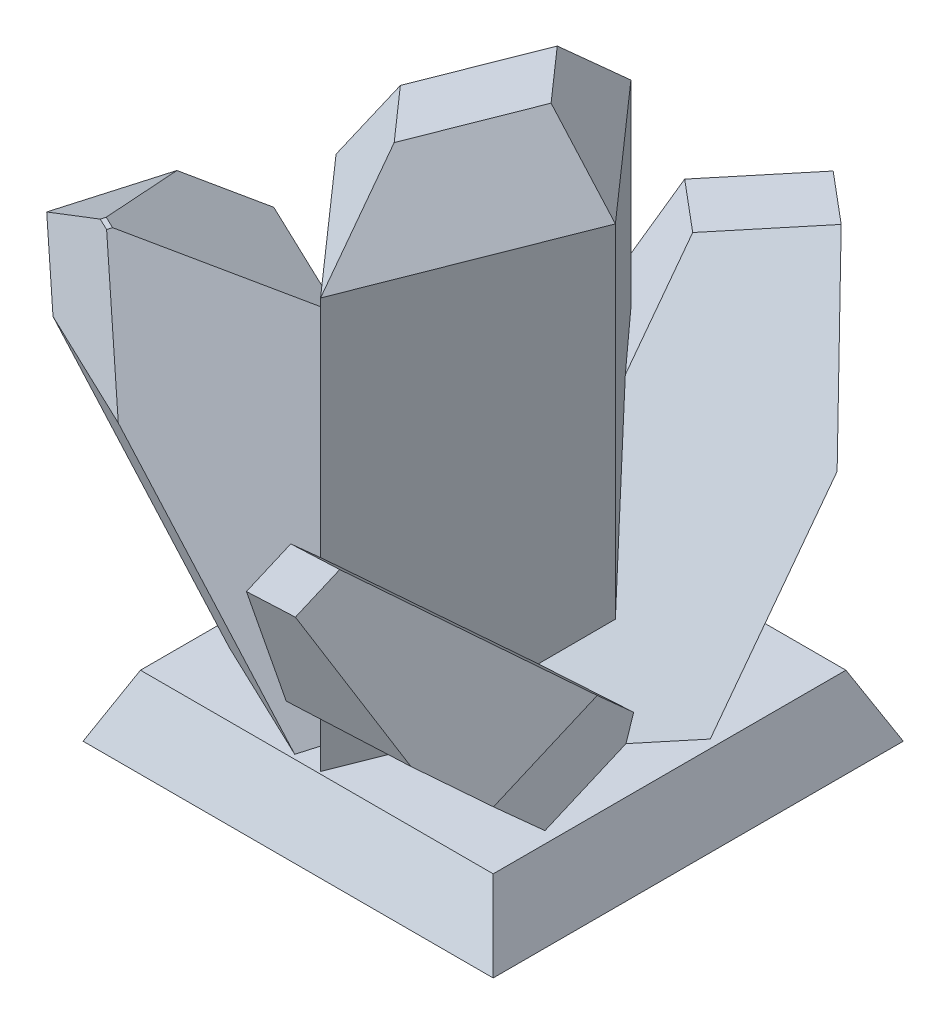
from build123d import *
from OCP.BRepFilletAPI import BRepFilletAPI_MakeChamfer

# Parameters (mm, degrees)
SKETCH1_W           = 10
SKETCH1_H           = 10
BOSS_EXTRUDE1_DEPTH = 1.5
BOSS_EXTRUDE1_TAPER = 25
BOSS_EXTRUDE2_DEPTH = 12
CHAMFER1_SIZE       = 2
CHAMFER1_SIZE2      = 1.154700538
BOSS_EXTRUDE3_DEPTH = 10
CHAMFER2_SIZE       = 3
CHAMFER2_SIZE2      = 2.406716572
CHAMFER2_SIZE2_2    = 1.500380386
CHAMFER2_SIZE2_3    = 1.516874639
BOSS_EXTRUDE4_DEPTH = 8
BOSS_EXTRUDE5_DEPTH = 10
CHAMFER3_SIZE       = 4
CHAMFER3_SIZE2      = 2.031521954
CHAMFER3_SIZE2_2    = 2.008940765
CHAMFER3_SIZE2_3    = 2.098992436
CHAMFER3_SIZE2_4    = 2.518260147


with BuildPart() as part:
    # Sketch1 → Boss-Extrude1 (new body)
    with BuildSketch(Plane(origin=(0, 0, 0), x_dir=(1, 0, 0), z_dir=(0, 1, 0))):
        Rectangle(SKETCH1_W, SKETCH1_H)
    extrude(amount=BOSS_EXTRUDE1_DEPTH, taper=BOSS_EXTRUDE1_TAPER)

    # Sketch2 → Boss-Extrude2 (add)
    with BuildSketch(Plane(origin=(0, 1.5, 0), x_dir=(1, 0, 0), z_dir=(0, 1, 0))):
        Polygon((-2.812986954, -1.017959657), (-0.78305427, 4.14157821), (2.064873257, 0.914552857), (0.034940573, -4.24498501), align=None)
    extrude(amount=BOSS_EXTRUDE2_DEPTH)

    # Chamfer1: one chamfer whose edges measure the first distance from different faces: ONE call of the kernel's chamfer builder (chamfer() names one face for all edges)
    chamfer1_edges_1 = [part.edges().sort_by_distance(p)[0] for p in [
        (-1.389023191, 13.5, 2.631472333),
    ]]
    chamfer1_side_1 = [part.faces().sort_by_distance(p)[0] for p in [
        (-1.389023191, 7.5, 2.631472333),
    ]]
    chamfer1_edges_2 = [part.edges().sort_by_distance(p)[0] for p in [
        (1.049906915, 13.5, 1.665216077),
    ]]
    chamfer1_side_2 = [part.faces().sort_by_distance(p)[0] for p in [
        (1.049906915, 7.5, 1.665216077),
    ]]
    chamfer1_edges_3 = [part.edges().sort_by_distance(p)[0] for p in [
        (0.640909494, 13.5, -2.528065533),
    ]]
    chamfer1_side_3 = [part.faces().sort_by_distance(p)[0] for p in [
        (0.640909494, 7.5, -2.528065533),
    ]]
    chamfer1_edges_4 = [part.edges().sort_by_distance(p)[0] for p in [
        (-1.798020612, 13.5, -1.561809276),
    ]]
    chamfer1_side_4 = [part.faces().sort_by_distance(p)[0] for p in [
        (-1.798020612, 7.5, -1.561809276),
    ]]
    chamfer1 = BRepFilletAPI_MakeChamfer(part.part.solid().wrapped)
    for e in chamfer1_edges_1:
        chamfer1.Add(CHAMFER1_SIZE, CHAMFER1_SIZE2, e.wrapped, chamfer1_side_1[0].wrapped)  # the first distance lies on this face
    for e in chamfer1_edges_2:
        chamfer1.Add(CHAMFER1_SIZE, CHAMFER1_SIZE2, e.wrapped, chamfer1_side_2[0].wrapped)  # the first distance lies on this face
    for e in chamfer1_edges_3:
        chamfer1.Add(CHAMFER1_SIZE, CHAMFER1_SIZE2, e.wrapped, chamfer1_side_3[0].wrapped)  # the first distance lies on this face
    for e in chamfer1_edges_4:
        chamfer1.Add(CHAMFER1_SIZE, CHAMFER1_SIZE2, e.wrapped, chamfer1_side_4[0].wrapped)  # the first distance lies on this face
    add(Compound.cast(chamfer1.Shape()), mode=Mode.REPLACE)

    # Sketch4 → Boss-Extrude3 (add, along a direction that is not the sketch's normal)
    with BuildSketch(Plane(origin=(0, 1.5, 0), x_dir=(1, 0, 0), z_dir=(0, 1, 0))):
        Polygon((-3.685896684, -2.744355022), (-2.381707977, 1.767077084), (0.661288248, 0.315446351), (-0.642900459, -4.195985754), align=None)
    extrude(amount=BOSS_EXTRUDE3_DEPTH, dir=(-0.5520160266548657, 0.8281604089609962, 0.09710120156687128))

    # Chamfer2: one chamfer whose edges measure the first distance from different faces: ONE call of the kernel's chamfer builder (chamfer() names one face for all edges)
    chamfer2_edges_1 = [part.edges().sort_by_distance(p)[0] for p in [
        (-6.380370131, 9.78160409, -0.070249702),
    ]]
    chamfer2_side_1 = [part.faces().sort_by_distance(p)[0] for p in [
        (-7.032464485, 9.78160409, 2.185466351),
    ]]
    chamfer2_edges_2 = [part.edges().sort_by_distance(p)[0] for p in [
        (-8.553962597, 9.78160409, 1.459650985),
    ]]
    chamfer2_side_2 = [part.faces().sort_by_distance(p)[0] for p in [
        (-7.032464485, 9.78160409, 2.185466351),
    ]]
    chamfer2_edges_3 = [part.edges().sort_by_distance(p)[0] for p in [
        (-7.684558838, 9.78160409, 4.441182404),
    ]]
    chamfer2_side_3 = [part.faces().sort_by_distance(p)[0] for p in [
        (-4.924478705, 5.640802045, 3.955676396),
    ]]
    chamfer2 = BRepFilletAPI_MakeChamfer(part.part.solid().wrapped)
    for e in chamfer2_edges_1:
        chamfer2.Add(CHAMFER2_SIZE, CHAMFER2_SIZE2, e.wrapped, chamfer2_side_1[0].wrapped)  # the first distance lies on this face
    for e in chamfer2_edges_2:
        chamfer2.Add(CHAMFER2_SIZE, CHAMFER2_SIZE2_2, e.wrapped, chamfer2_side_2[0].wrapped)  # the first distance lies on this face
    for e in chamfer2_edges_3:
        chamfer2.Add(CHAMFER2_SIZE, CHAMFER2_SIZE2_3, e.wrapped, chamfer2_side_3[0].wrapped)  # the first distance lies on this face
    add(Compound.cast(chamfer2.Shape()), mode=Mode.REPLACE)

    # Sketch5 → Boss-Extrude4 (add, along a direction that is not the sketch's normal)
    with BuildSketch(Plane(origin=(0, 1.5, 0), x_dir=(1, 0, 0), z_dir=(0, 1, 0))):
        Polygon((-0.799065943, 0.680702687), (0.288664987, -2.936597885), (4.019801987, -2.756774896), (2.932071057, 0.860525676), align=None)
    extrude(amount=BOSS_EXTRUDE4_DEPTH, dir=(0.12852896278760917, 0.6705109361257466, 0.7306814560809083))

    # Sketch6 → Boss-Extrude5 (add, along a direction that is not the sketch's normal)
    with BuildSketch(Plane(origin=(0, 1.5, 0), x_dir=(1, 0, 0), z_dir=(0, 1, 0))):
        Polygon((-1.600069282, 0), (1.180756558, -2.337369015), (4.1003801, 1.192394032), (1.31955426, 3.529763047), align=None)
    extrude(amount=BOSS_EXTRUDE5_DEPTH, dir=(-0.12852896278760925, 0.6705109361257466, -0.7306814560809083))

    # Chamfer3: one chamfer whose edges measure the first distance from different faces: ONE call of the kernel's chamfer builder (chamfer() names one face for all edges)
    chamfer3_edges_1 = [part.edges().sort_by_distance(p)[0] for p in [
        (-1.425547139, 8.205109361, -9.071696084),
    ]]
    chamfer3_side_1 = [part.faces().sort_by_distance(p)[0] for p in [
        (-0.77862694, 5.370569751, -6.108006882),
    ]]
    chamfer3_edges_2 = [part.edges().sort_by_distance(p)[0] for p in [
        (1.424677552, 8.205109361, -9.6678931),
    ]]
    chamfer3_side_2 = [part.faces().sort_by_distance(p)[0] for p in [
        (2.067322366, 4.852554681, -6.01448582),
    ]]
    chamfer3_edges_3 = [part.edges().sort_by_distance(p)[0] for p in [
        (3.182465189, 6.864087489, 8.692138039),
    ]]
    chamfer3_side_3 = [part.faces().sort_by_distance(p)[0] for p in [
        (2.674699398, 4.189172634, 5.776940656),
    ]]
    chamfer3_edges_4 = [part.edges().sort_by_distance(p)[0] for p in [
        (4.504168224, 6.864087489, 6.793576259),
    ]]
    chamfer3_side_4 = [part.faces().sort_by_distance(p)[0] for p in [
        (3.998071432, 4.203478125, 3.907212333),
    ]]
    chamfer3 = BRepFilletAPI_MakeChamfer(part.part.solid().wrapped)
    for e in chamfer3_edges_1:
        chamfer3.Add(CHAMFER3_SIZE, CHAMFER3_SIZE2, e.wrapped, chamfer3_side_1[0].wrapped)  # the first distance lies on this face
    for e in chamfer3_edges_2:
        chamfer3.Add(CHAMFER3_SIZE, CHAMFER3_SIZE2_2, e.wrapped, chamfer3_side_2[0].wrapped)  # the first distance lies on this face
    for e in chamfer3_edges_3:
        chamfer3.Add(CHAMFER3_SIZE, CHAMFER3_SIZE2_3, e.wrapped, chamfer3_side_3[0].wrapped)  # the first distance lies on this face
    for e in chamfer3_edges_4:
        chamfer3.Add(CHAMFER3_SIZE, CHAMFER3_SIZE2_4, e.wrapped, chamfer3_side_4[0].wrapped)  # the first distance lies on this face
    add(Compound.cast(chamfer3.Shape()), mode=Mode.REPLACE)


solid = part.part
